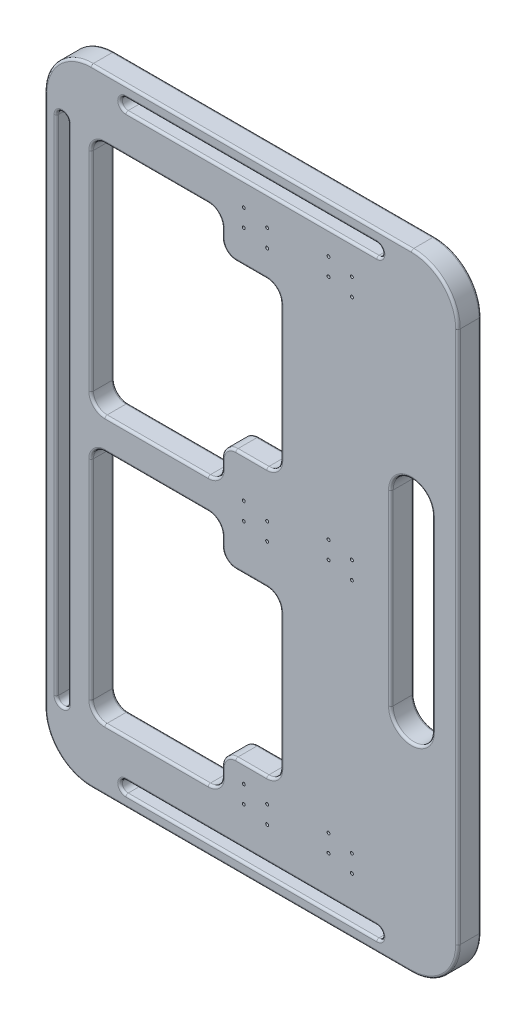
from build123d import *

# Parameters (mm, degrees)
BOSS_EXTRUDE1_DEPTH = 25.4
FILLET1_R           = 2.54
HOLE2_D             = 3.175
HOLE2_DEPTH         = 31.75
HOLE2_CBORE_D       = 5.7404
HOLE2_CBORE_DEPTH   = 3.5052


with BuildPart() as part:
    # Sketch1 → Boss-Extrude1 (new body)
    with BuildSketch(Plane.XY):
        with BuildLine():
            Line((178.841291268, 5.830748671), (-169.316291268, 5.830748671))
            ThreePointArc((-169.316291268, 5.830748671), (-205.029031455, -8.961952664), (-219.821732791, -44.674692852))
            Line((-219.821732791, -44.674692852), (-219.821732791, -624.167422709))
            ThreePointArc((-219.821732791, -624.167422709), (-205.029031455, -659.880162896), (-169.316291268, -674.672864232))
            Line((-169.316291268, -674.672864232), (178.841291268, -674.672864232))
            ThreePointArc((178.841291268, -674.672864232), (214.554031455, -659.880162896), (229.346732791, -624.167422709))
            Line((229.346732791, -624.167422709), (229.346732791, -44.674692852))
            ThreePointArc((229.346732791, -44.674692852), (214.554031455, -8.961952664), (178.841291268, 5.830748671))
        make_face()
        with BuildLine():
            Line((201.277190257, -232.82105778), (201.277190257, -436.02105778))
            ThreePointArc((201.277190257, -436.02105778), (178.841291268, -458.45695677), (156.405392278, -436.02105778))
            Line((156.405392278, -436.02105778), (156.405392278, -232.82105778))
            ThreePointArc((156.405392278, -232.82105778), (178.841291268, -210.385158791), (201.277190257, -232.82105778))
        make_face(mode=Mode.SUBTRACT)
        with BuildLine():
            Line((-42.021732791, -61.084457743), (-154.370849745, -61.084457743))
            ThreePointArc((-154.370849745, -61.084457743), (-164.938872794, -65.461876217), (-169.316291268, -76.029899266))
            Line((-169.316291268, -76.029899266), (-169.316291268, -302.554558477))
            ThreePointArc((-169.316291268, -302.554558477), (-164.938872794, -313.122581526), (-154.370849745, -317.5))
            Line((-154.370849745, -317.5), (-42.021732791, -317.5))
            ThreePointArc((-42.021732791, -317.5), (-31.453709742, -313.122581526), (-27.076291268, -302.554558477))
            Line((-27.076291268, -302.554558477), (-27.076291268, -292.963135522))
            ThreePointArc((-27.076291268, -292.963135522), (-22.698872794, -282.395112473), (-12.130849745, -278.017693999))
            Line((-12.130849745, -278.017693999), (21.478267209, -278.017693999))
            ThreePointArc((21.478267209, -278.017693999), (32.046290258, -273.640275525), (36.423708732, -263.072252476))
            Line((36.423708732, -263.072252476), (36.423708732, -115.512205267))
            ThreePointArc((36.423708732, -115.512205267), (32.046290258, -104.944182218), (21.478267209, -100.566763744))
            Line((21.478267209, -100.566763744), (-12.130849745, -100.566763744))
            ThreePointArc((-12.130849745, -100.566763744), (-22.698872794, -96.18934527), (-27.076291268, -85.621322221))
            Line((-27.076291268, -85.621322221), (-27.076291268, -76.029899266))
            ThreePointArc((-27.076291268, -76.029899266), (-31.453709742, -65.461876217), (-42.021732791, -61.084457743))
        make_face(mode=Mode.SUBTRACT)
        with BuildLine():
            Line((-131.519577428, -6.869251329), (141.044577428, -6.869251329))
            ThreePointArc((141.044577428, -6.869251329), (147.394577428, -13.219251329), (141.044577428, -19.569251329))
            Line((141.044577428, -19.569251329), (-131.519577428, -19.569251329))
            ThreePointArc((-131.519577428, -19.569251329), (-137.869577428, -13.219251329), (-131.519577428, -6.869251329))
        make_face(mode=Mode.SUBTRACT)
        with BuildLine():
            Line((-27.076291268, -375.878980039), (-27.076291268, -366.287557083))
            ThreePointArc((-27.076291268, -366.287557083), (-31.453709742, -355.719534035), (-42.021732791, -351.34211556))
            Line((-42.021732791, -351.34211556), (-154.370849745, -351.34211556))
            ThreePointArc((-154.370849745, -351.34211556), (-164.938872794, -355.719534035), (-169.316291268, -366.287557083))
            Line((-169.316291268, -366.287557083), (-169.316291268, -592.812216295))
            ThreePointArc((-169.316291268, -592.812216295), (-164.938872794, -603.380239343), (-154.370849745, -607.757657817))
            Line((-154.370849745, -607.757657817), (-42.021732791, -607.757657817))
            ThreePointArc((-42.021732791, -607.757657817), (-31.453709742, -603.380239343), (-27.076291268, -592.812216295))
            Line((-27.076291268, -592.812216295), (-27.076291268, -583.220793339))
            ThreePointArc((-27.076291268, -583.220793339), (-22.698872794, -572.652770291), (-12.130849745, -568.275351817))
            Line((-12.130849745, -568.275351817), (21.478267209, -568.275351817))
            ThreePointArc((21.478267209, -568.275351817), (32.046290258, -563.897933342), (36.423708732, -553.329910294))
            Line((36.423708732, -553.329910294), (36.423708732, -405.769863084))
            ThreePointArc((36.423708732, -405.769863084), (32.046290258, -395.201840036), (21.478267209, -390.824421561))
            Line((21.478267209, -390.824421561), (-12.130849745, -390.824421561))
            ThreePointArc((-12.130849745, -390.824421561), (-22.698872794, -386.447003087), (-27.076291268, -375.878980039))
        make_face(mode=Mode.SUBTRACT)
        with BuildLine():
            Line((-207.121732791, -607.757657817), (-207.121732791, -61.084457743))
            ThreePointArc((-207.121732791, -61.084457743), (-200.771732791, -54.734457743), (-194.421732791, -61.084457743))
            Line((-194.421732791, -61.084457743), (-194.421732791, -607.757657817))
            ThreePointArc((-194.421732791, -607.757657817), (-200.771732791, -614.107657817), (-207.121732791, -607.757657817))
        make_face(mode=Mode.SUBTRACT)
        with BuildLine():
            Line((-131.519577428, -661.972864232), (141.044577428, -661.972864232))
            ThreePointArc((141.044577428, -661.972864232), (147.394577428, -655.622864232), (141.044577428, -649.272864232))
            Line((141.044577428, -649.272864232), (-131.519577428, -649.272864232))
            ThreePointArc((-131.519577428, -649.272864232), (-137.869577428, -655.622864232), (-131.519577428, -661.972864232))
        make_face(mode=Mode.SUBTRACT)
    extrude(amount=BOSS_EXTRUDE1_DEPTH)

    # Fillet1
    fillet1_edges = [part.edges().sort_by_distance(p)[0] for p in [
        (229.346732791, -334.42105778, 0),
        (-22.698872794, -386.447003087, 0),
        (-27.076291268, -371.083268561, 0),
        (214.554031455, -659.880162896, 0),
        (-31.453709742, -355.719534035, 0),
        (-98.196291268, -351.34211556, 0),
        (-164.938872794, -355.719534035, 0),
        (-169.316291268, -479.549886689, 0),
        (-164.938872794, -603.380239343, 0),
        (-98.196291268, -607.757657817, 0),
        (-31.453709742, -603.380239343, 0),
        (-27.076291268, -588.016504817, 0),
        (-22.698872794, -572.652770291, 0),
        (4.673708732, -568.275351817, 0),
        (4.7625, -674.672864232, 0),
        (32.046290258, -563.897933342, 0),
        (36.423708732, -479.549886689, 0),
        (32.046290258, -395.201840036, 0),
        (4.673708732, -390.824421561, 0),
        (-22.698872794, -386.447003087, 25.4),
        (-27.076291268, -371.083268561, 25.4),
        (-31.453709742, -355.719534035, 25.4),
        (-98.196291268, -351.34211556, 25.4),
        (-164.938872794, -355.719534035, 25.4),
        (-169.316291268, -479.549886689, 25.4),
        (-164.938872794, -603.380239343, 25.4),
        (-205.029031455, -659.880162896, 0),
        (-98.196291268, -607.757657817, 25.4),
        (-31.453709742, -603.380239343, 25.4),
        (-27.076291268, -588.016504817, 25.4),
        (-22.698872794, -572.652770291, 25.4),
        (4.673708732, -568.275351817, 25.4),
        (32.046290258, -563.897933342, 25.4),
        (36.423708732, -479.549886689, 25.4),
        (32.046290258, -395.201840036, 25.4),
        (4.673708732, -390.824421561, 25.4),
        (214.554031455, -659.880162896, 25.4),
        (-200.771732791, -614.107657817, 0),
        (-194.421732791, -334.42105778, 0),
        (-200.771732791, -54.734457743, 0),
        (-207.121732791, -334.42105778, 0),
        (-200.771732791, -614.107657817, 25.4),
        (-194.421732791, -334.42105778, 25.4),
        (-200.771732791, -54.734457743, 25.4),
        (-207.121732791, -334.42105778, 25.4),
        (-137.869577428, -655.622864232, 0),
        (4.7625, -661.972864232, 0),
        (147.394577428, -655.622864232, 0),
        (4.7625, -649.272864232, 0),
        (-137.869577428, -655.622864232, 25.4),
        (4.7625, -661.972864232, 25.4),
        (147.394577428, -655.622864232, 25.4),
        (4.7625, -649.272864232, 25.4),
        (229.346732791, -334.42105778, 25.4),
        (214.554031455, -8.961952664, 25.4),
        (178.841291268, -210.385158791, 0),
        (156.405392278, -334.42105778, 0),
        (4.7625, 5.830748671, 25.4),
        (178.841291268, -458.45695677, 0),
        (201.277190257, -334.42105778, 0),
        (178.841291268, -210.385158791, 25.4),
        (156.405392278, -334.42105778, 25.4),
        (178.841291268, -458.45695677, 25.4),
        (201.277190257, -334.42105778, 25.4),
        (-205.029031455, -8.961952664, 25.4),
        (-219.821732791, -334.42105778, 25.4),
        (-137.869577428, -13.219251329, 0),
        (4.7625, -19.569251329, 0),
        (147.394577428, -13.219251329, 0),
        (4.7625, -6.869251329, 0),
        (-137.869577428, -13.219251329, 25.4),
        (4.7625, -19.569251329, 25.4),
        (147.394577428, -13.219251329, 25.4),
        (4.7625, -6.869251329, 25.4),
        (-205.029031455, -659.880162896, 25.4),
        (32.046290258, -104.944182218, 0),
        (4.673708732, -100.566763744, 0),
        (-22.698872794, -96.18934527, 0),
        (-27.076291268, -80.825610743, 0),
        (-31.453709742, -65.461876217, 0),
        (-98.196291268, -61.084457743, 0),
        (-164.938872794, -65.461876217, 0),
        (-169.316291268, -189.292228872, 0),
        (-164.938872794, -313.122581526, 0),
        (-98.196291268, -317.5, 0),
        (-31.453709742, -313.122581526, 0),
        (-27.076291268, -297.758847, 0),
        (-22.698872794, -282.395112473, 0),
        (4.673708732, -278.017693999, 0),
        (32.046290258, -273.640275525, 0),
        (36.423708732, -189.292228872, 0),
        (32.046290258, -104.944182218, 25.4),
        (4.673708732, -100.566763744, 25.4),
        (-22.698872794, -96.18934527, 25.4),
        (-27.076291268, -80.825610743, 25.4),
        (-31.453709742, -65.461876217, 25.4),
        (-98.196291268, -61.084457743, 25.4),
        (-164.938872794, -65.461876217, 25.4),
        (-169.316291268, -189.292228872, 25.4),
        (-164.938872794, -313.122581526, 25.4),
        (-98.196291268, -317.5, 25.4),
        (-31.453709742, -313.122581526, 25.4),
        (-27.076291268, -297.758847, 25.4),
        (-22.698872794, -282.395112473, 25.4),
        (4.673708732, -278.017693999, 25.4),
        (32.046290258, -273.640275525, 25.4),
        (36.423708732, -189.292228872, 25.4),
        (-219.821732791, -334.42105778, 0),
        (4.7625, -674.672864232, 25.4),
        (-205.029031455, -8.961952664, 0),
        (4.7625, 5.830748671, 0),
        (214.554031455, -8.961952664, 0),
    ]]
    fillet(fillet1_edges, radius=FILLET1_R)

    # Hole2
    with Locations(Plane(origin=(0, 0, 0), x_dir=(-1, 0, 0), z_dir=(0, 0, -1))):
        with Locations((-114.053377526, -52.003972738), (-114.053377526, -71.053972738), (-88.653377526, -45.653972738), (-88.653377526, -64.703972738), (3.421622474, -45.653972738), (3.421622474, -64.703972738), (-21.978377526, -52.003972738), (-21.978377526, -71.053972738), (-21.978377526, -328.07105778), (-21.978377526, -347.12105778), (3.421622474, -340.77105778), (3.421622474, -321.72105778), (-114.053377526, -594.570172231), (-114.053377526, -613.620172231), (-88.653377526, -607.270172231), (-88.653377526, -588.220172231), (3.421622474, -588.220172231), (3.421622474, -607.270172231), (-21.978377526, -594.570172231), (-21.978377526, -613.620172231), (-114.053377526, -337.553087189), (-114.053377526, -318.503087189), (-88.653377526, -331.203087189), (-88.653377526, -312.153087189)):
            CounterBoreHole(HOLE2_D / 2, HOLE2_CBORE_D / 2, HOLE2_CBORE_DEPTH, depth=HOLE2_DEPTH)


solid = part.part
